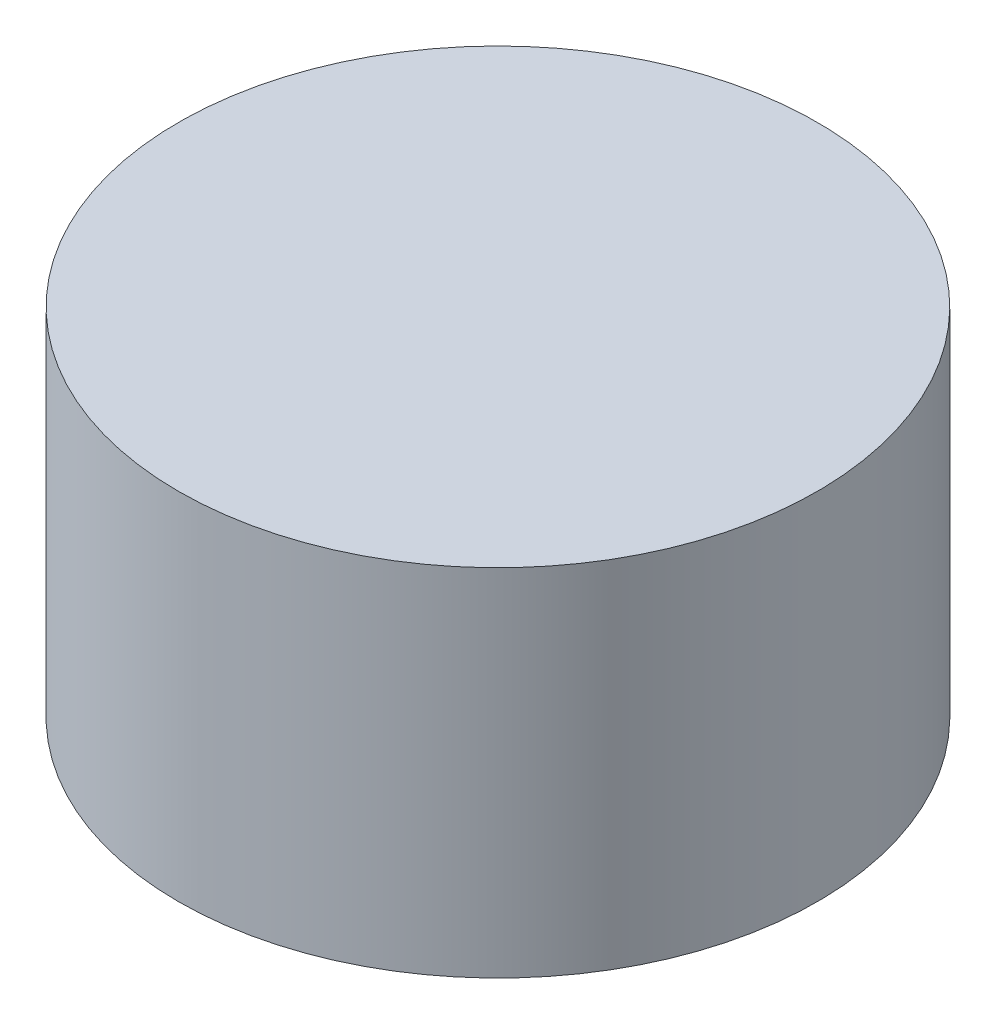
from build123d import *

# Parameters (mm, degrees)
SKETCH1_R           = 35.963227588
BOSS_EXTRUDE1_DEPTH = 40


with BuildPart() as part:
    # Sketch1 → Boss-Extrude1 (new body)
    with BuildSketch(Plane(origin=(0, 0, 0), x_dir=(1, 0, 0), z_dir=(0, 1, 0))):
        Circle(SKETCH1_R)
    extrude(amount=BOSS_EXTRUDE1_DEPTH)


solid = part.part
